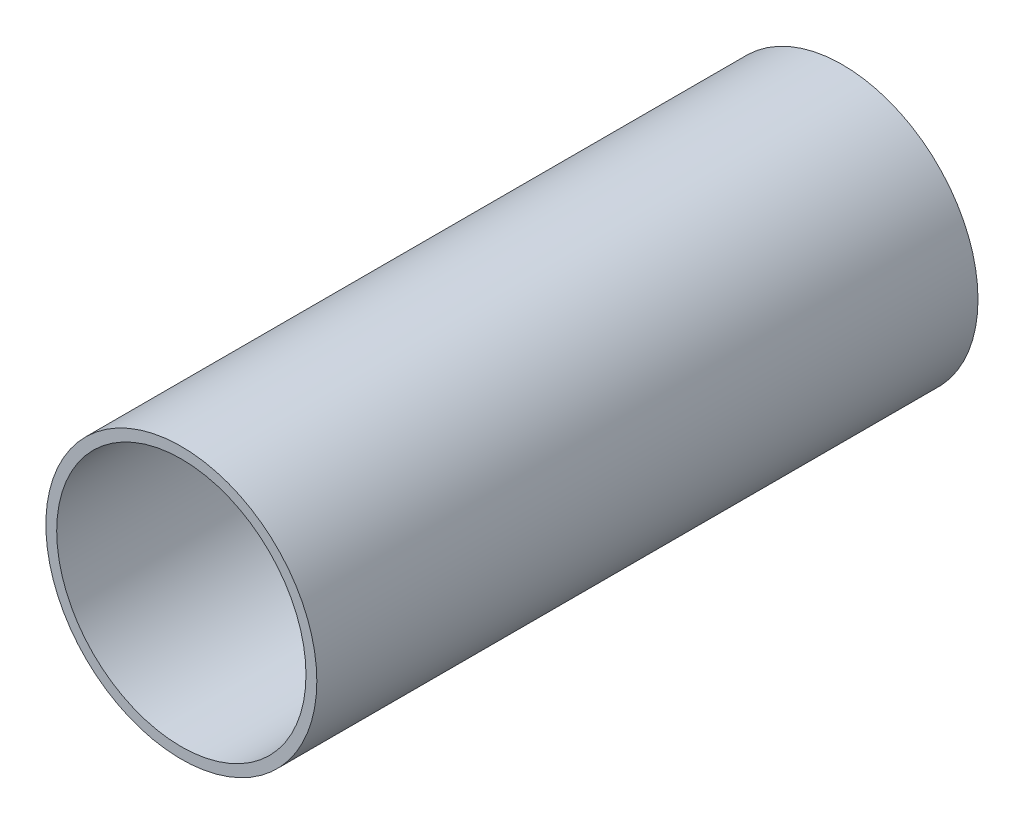
from build123d import *

# Parameters (mm, degrees)
SKETCH1_R           = 76.2
SKETCH1_R_2         = 73.025
BOSS_EXTRUDE1_DEPTH = 241.3
SKETCH1_3_R         = 79.375
SKETCH1_3_R_2       = 76.2
BOSS_EXTRUDE2_DEPTH = 387.35


with BuildPart() as part:
    # Sketch1 → Boss-Extrude1 (new body)
    with BuildSketch(Plane.XY):
        Circle(SKETCH1_R)
        Circle(SKETCH1_R_2, mode=Mode.SUBTRACT)
    extrude(amount=-BOSS_EXTRUDE1_DEPTH)

    # Sketch1_3 → Boss-Extrude2 (add)
    with BuildSketch(Plane.XY):
        Circle(SKETCH1_3_R)
        Circle(SKETCH1_3_R_2, mode=Mode.SUBTRACT)
    extrude(amount=-BOSS_EXTRUDE2_DEPTH)


solid = part.part
